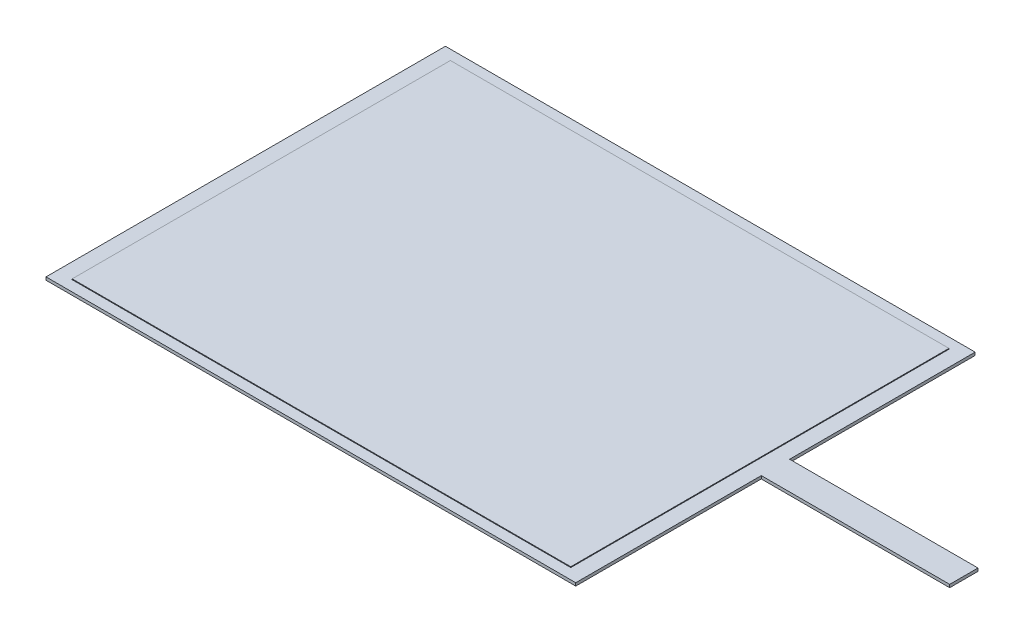
from build123d import *

# Parameters (mm, degrees)
BOSS_EXTRUDE1_DEPTH = 0.52
SKETCH1_4_W         = 176
SKETCH1_4_H         = 133.5
BOSS_EXTRUDE2_DEPTH = 0.79


with BuildPart() as part:
    # Sketch1 → Boss-Extrude1 (new, symmetric)
    with BuildSketch(Plane(origin=(0, 0, 0), x_dir=(1, 0, 0), z_dir=(0, 1, 0))):
        Polygon((-93.5, 70.5), (-93.5, -70.5), (93.5, -70.5), (93.5, -5), (160, -5), (160, 5), (93.5, 5), (93.5, 70.5), align=None)
    extrude(amount=BOSS_EXTRUDE1_DEPTH, both=True)

    # Sketch1_4 → Boss-Extrude2 (add, symmetric)
    with BuildSketch(Plane(origin=(0, 0, 0), x_dir=(1, 0, 0), z_dir=(0, 1, 0))):
        Rectangle(SKETCH1_4_W, SKETCH1_4_H)
    extrude(amount=BOSS_EXTRUDE2_DEPTH, both=True)


solid = part.part
